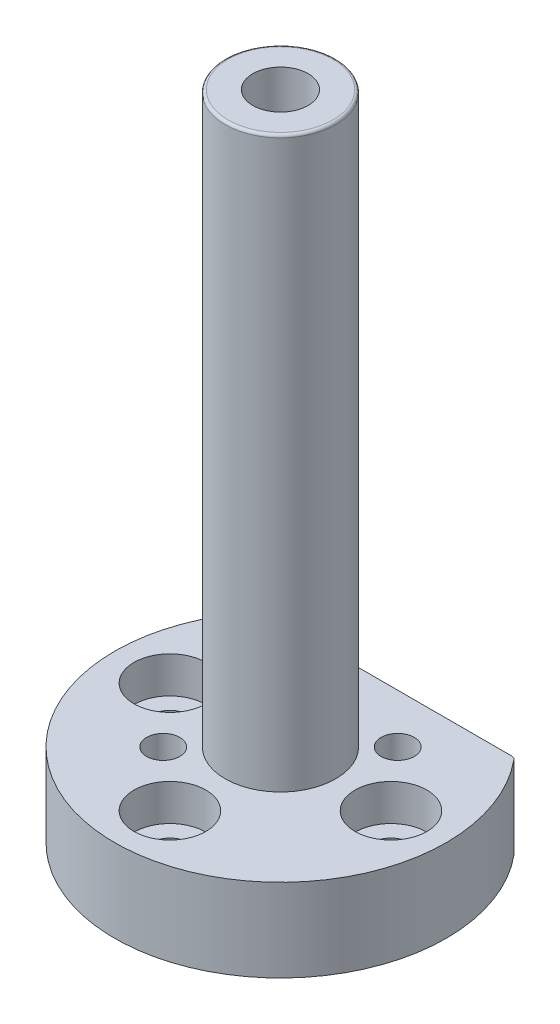
from build123d import *

# Parameters (mm, degrees)
BOSS_EXTRUDE1_DEPTH = 15
SKETCH2_R           = 10
BOSS_EXTRUDE2_DEPTH = 103
SKETCH4_R           = 7.25
CUT_EXTRUDE1_DEPTH  = 57
SKETCH5_R           = 5
CUT_EXTRUDE2_DEPTH  = 62
SKETCH7_R           = 6.5
CUT_EXTRUDE3_DEPTH  = 6.6
SKETCH8_R           = 3.3
CUT_EXTRUDE4_DEPTH  = 9.4
CIRPATTERN1_COUNT   = 4
FILLET1_R           = 0.5
FILLET2_R           = 1
SKETCH9_R           = 3
CUT_EXTRUDE5_DEPTH  = 16


with BuildPart() as part:
    # Sketch1 → Boss-Extrude1 (new body)
    with BuildSketch(Plane(origin=(0, 0, 0), x_dir=(1, 0, 0), z_dir=(0, 1, 0))):
        with BuildLine():
            Line((22.79802623, 19.5), (-22.79802623, 19.5))
            ThreePointArc((-22.79802623, 19.5), (0, -30), (22.79802623, 19.5))
        make_face()
    extrude(amount=BOSS_EXTRUDE1_DEPTH)

    # Sketch2 → Boss-Extrude2 (add)
    with BuildSketch(Plane(origin=(0, 15, 0), x_dir=(1, 0, 0), z_dir=(0, 1, 0))):
        Circle(SKETCH2_R)
    extrude(amount=BOSS_EXTRUDE2_DEPTH)

    # Sketch4 → Cut-Extrude1 (cut)
    with BuildSketch(Plane.XZ):
        Circle(SKETCH4_R)
    extrude(amount=-CUT_EXTRUDE1_DEPTH, mode=Mode.SUBTRACT)

    # Sketch5 → Cut-Extrude2 (cut, through all)
    with BuildSketch(Plane.XZ.offset(-57)):
        Circle(SKETCH5_R)
    extrude(amount=-CUT_EXTRUDE2_DEPTH, mode=Mode.SUBTRACT)

    # Sketch7 → Cut-Extrude3 (cut)
    with BuildSketch(Plane(origin=(0, 15, 0), x_dir=(1, 0, 0), z_dir=(0, 1, 0))):
        with Locations((0, -20)):
            Circle(SKETCH7_R)
    cut_extrude3 = extrude(amount=-CUT_EXTRUDE3_DEPTH, mode=Mode.SUBTRACT)

    # Sketch8 → Cut-Extrude4 (cut, through all)
    with BuildSketch(Plane(origin=(0, 8.4, 0), x_dir=(1, 0, 0), z_dir=(0, 1, 0))):
        with Locations((0, -20)):
            Circle(SKETCH8_R)
    cut_extrude4 = extrude(amount=-CUT_EXTRUDE4_DEPTH, mode=Mode.SUBTRACT)

    # CirPattern1: Cut-Extrude3, Cut-Extrude4 ×4 about axis, 1 skipped
    cirpattern1_axis = Axis((0, 0, 0), (0, -1, 0))
    add([cut_extrude3.rotate(cirpattern1_axis, i * 360 / CIRPATTERN1_COUNT) for i in range(1, CIRPATTERN1_COUNT) if i not in (2,)], mode=Mode.SUBTRACT)
    add([cut_extrude4.rotate(cirpattern1_axis, i * 360 / CIRPATTERN1_COUNT) for i in range(1, CIRPATTERN1_COUNT) if i not in (2,)], mode=Mode.SUBTRACT)

    # Fillet1
    fillet1_edges = [part.edges().sort_by_distance(p)[0] for p in [
        (-10, 118, 0),
    ]]
    fillet(fillet1_edges, radius=FILLET1_R)

    # Fillet2
    fillet2_edges = [part.edges().sort_by_distance(p)[0] for p in [
        (-22.79802623, 7.5, -19.5),
        (22.79802623, 7.5, -19.5),
    ]]
    fillet(fillet2_edges, radius=FILLET2_R)

    # Sketch9 → Cut-Extrude5 (cut, through all)
    with BuildSketch(Plane(origin=(0, 15, 0), x_dir=(1, 0, 0), z_dir=(0, 1, 0))):
        with Locations((-10.606601718, -10.606601718)):
            Circle(SKETCH9_R)
        with Locations((10.606601718, 10.606601718)):
            Circle(SKETCH9_R)
    extrude(amount=-CUT_EXTRUDE5_DEPTH, mode=Mode.SUBTRACT)


solid = part.part
